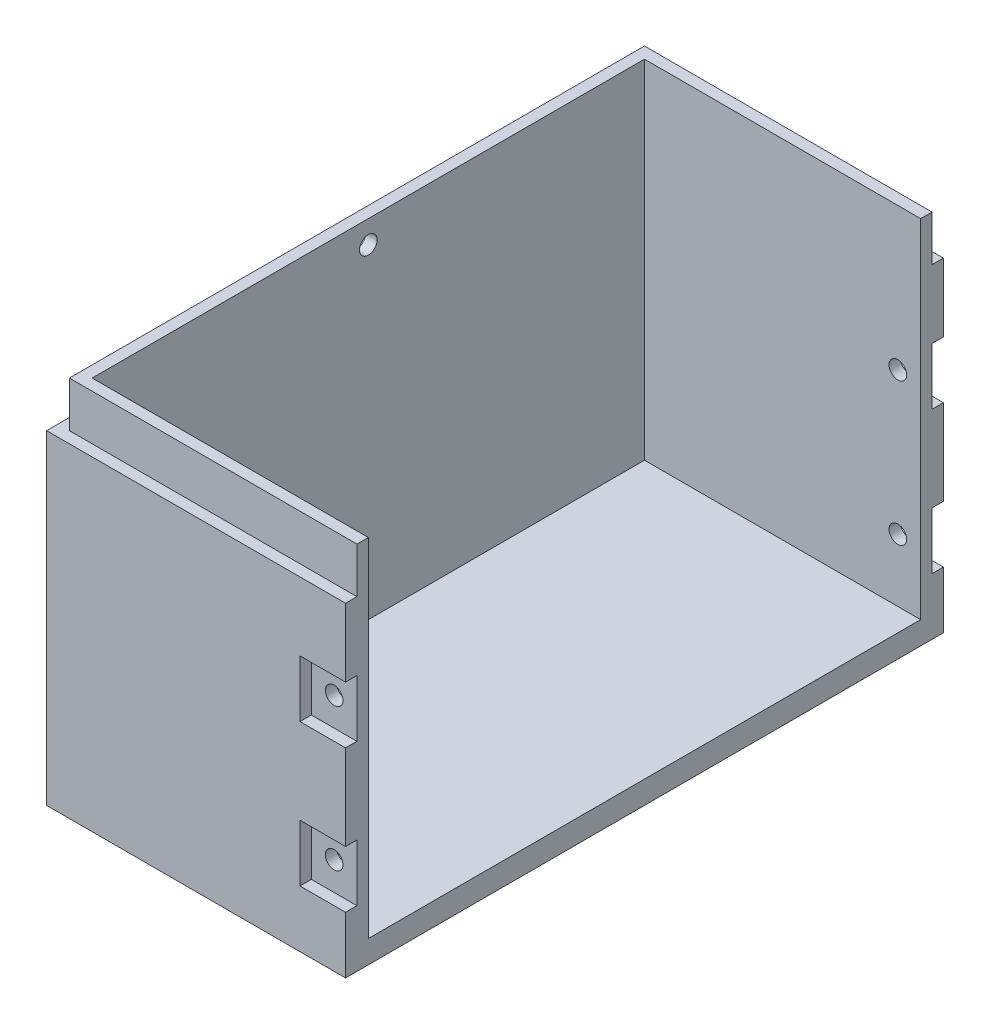
from build123d import *

# Parameters (mm, degrees)
SKETCH1_W           = 52.5
SKETCH1_H           = 105
BOSS_EXTRUDE1_DEPTH = 65
SKETCH2_W           = 97
SKETCH2_H           = 61
CUT_EXTRUDE1_DEPTH  = 48.5
SKETCH4_W           = 8
SKETCH4_H           = 57
CUT_EXTRUDE2_DEPTH  = 2
SKETCH5_W           = 8
SKETCH5_H           = 57
CUT_EXTRUDE3_DEPTH  = 2
SKETCH7_W           = 101
SKETCH7_H           = 8
CUT_EXTRUDE5_DEPTH  = 2
CUT_EXTRUDE6_REACH  = 52.5
SKETCH9_R           = 1.55
SKETCH10_R          = 1.55
CUT_EXTRUDE7_DEPTH  = 104
SKETCH12_W          = 8
SKETCH12_H          = 12
SKETCH12_H_2        = 10
SKETCH12_H_3        = 15
BOSS_EXTRUDE2_DEPTH = 2
SKETCH13_W          = 8
SKETCH13_H          = 12
SKETCH13_H_2        = 15
SKETCH13_H_3        = 10
BOSS_EXTRUDE3_DEPTH = 2


with BuildPart() as part:
    # Sketch1 → Boss-Extrude1 (new body)
    with BuildSketch(Plane(origin=(0, 0, 0), x_dir=(1, 0, 0), z_dir=(0, 1, 0))):
        Rectangle(SKETCH1_W, SKETCH1_H)
    extrude(amount=BOSS_EXTRUDE1_DEPTH)

    # Sketch2 → Cut-Extrude1 (cut)
    with BuildSketch(Plane(origin=(26.25, 0, 0), x_dir=(0, 0, -1), z_dir=(1, 0, 0))):
        with Locations((0, 34.5)):
            Rectangle(SKETCH2_W, SKETCH2_H)
    extrude(amount=-CUT_EXTRUDE1_DEPTH, mode=Mode.SUBTRACT)

    # Sketch4 → Cut-Extrude2 (cut)
    with BuildSketch(Plane(origin=(0, 0, -52.5), x_dir=(-1, 0, 0), z_dir=(0, 0, -1))):
        with Locations((-22.25, 28.5)):
            Rectangle(SKETCH4_W, SKETCH4_H)
        Polygon((26.25, 65), (-26.25, 65), (-26.25, 57), (-18.25, 57), (26.25, 57), align=None)
    extrude(amount=-CUT_EXTRUDE2_DEPTH, mode=Mode.SUBTRACT)

    # Sketch5 → Cut-Extrude3 (cut)
    with BuildSketch(Plane.XY.offset(52.5)):
        Polygon((26.25, 57), (26.25, 65), (-26.25, 65), (-26.25, 57), (18.25, 57), align=None)
        with Locations((22.25, 28.5)):
            Rectangle(SKETCH5_W, SKETCH5_H)
    extrude(amount=-CUT_EXTRUDE3_DEPTH, mode=Mode.SUBTRACT)

    # Sketch7 → Cut-Extrude5 (cut)
    with BuildSketch(Plane.ZY.offset(26.25)):
        with Locations((0, 61)):
            Rectangle(SKETCH7_W, SKETCH7_H)
    extrude(amount=-CUT_EXTRUDE5_DEPTH, mode=Mode.SUBTRACT)

    # Sketch9 → Cut-Extrude6 (cut, up to next)
    with BuildSketch(Plane.ZY.offset(24.25), mode=Mode.PRIVATE) as cut_extrude6_sk1:
        with Locations((0, 61)):
            Circle(SKETCH9_R)
    cut_extrude6_tool1 = extrude(cut_extrude6_sk1.sketch, amount=-CUT_EXTRUDE6_REACH, mode=Mode.PRIVATE) & part.part
    add(cut_extrude6_tool1.solids().sort_by_distance((-24.25, 61, 0))[0], mode=Mode.SUBTRACT)

    # Sketch10 → Cut-Extrude7 (cut, through all)
    with BuildSketch(Plane.XY.offset(50.5)):
        with Locations((22.25, 15)):
            Circle(SKETCH10_R)
        with Locations((22.25, 40)):
            Circle(SKETCH10_R)
    extrude(amount=-CUT_EXTRUDE7_DEPTH, mode=Mode.SUBTRACT)

    # Sketch12 → Boss-Extrude2 (add)
    with BuildSketch(Plane.XY.offset(50.5)):
        with Locations((22.25, 51)):
            Rectangle(SKETCH12_W, SKETCH12_H)
        with Locations((22.25, 5)):
            Rectangle(SKETCH12_W, SKETCH12_H_2)
        with Locations((22.25, 27.5)):
            Rectangle(SKETCH12_W, SKETCH12_H_3)
    extrude(amount=BOSS_EXTRUDE2_DEPTH)

    # Sketch13 → Boss-Extrude3 (add)
    with BuildSketch(Plane(origin=(0, 0, -50.5), x_dir=(-1, 0, 0), z_dir=(0, 0, -1))):
        with Locations((-22.25, 51)):
            Rectangle(SKETCH13_W, SKETCH13_H)
        with Locations((-22.25, 27.5)):
            Rectangle(SKETCH13_W, SKETCH13_H_2)
        with Locations((-22.25, 5)):
            Rectangle(SKETCH13_W, SKETCH13_H_3)
    extrude(amount=BOSS_EXTRUDE3_DEPTH)


solid = part.part
